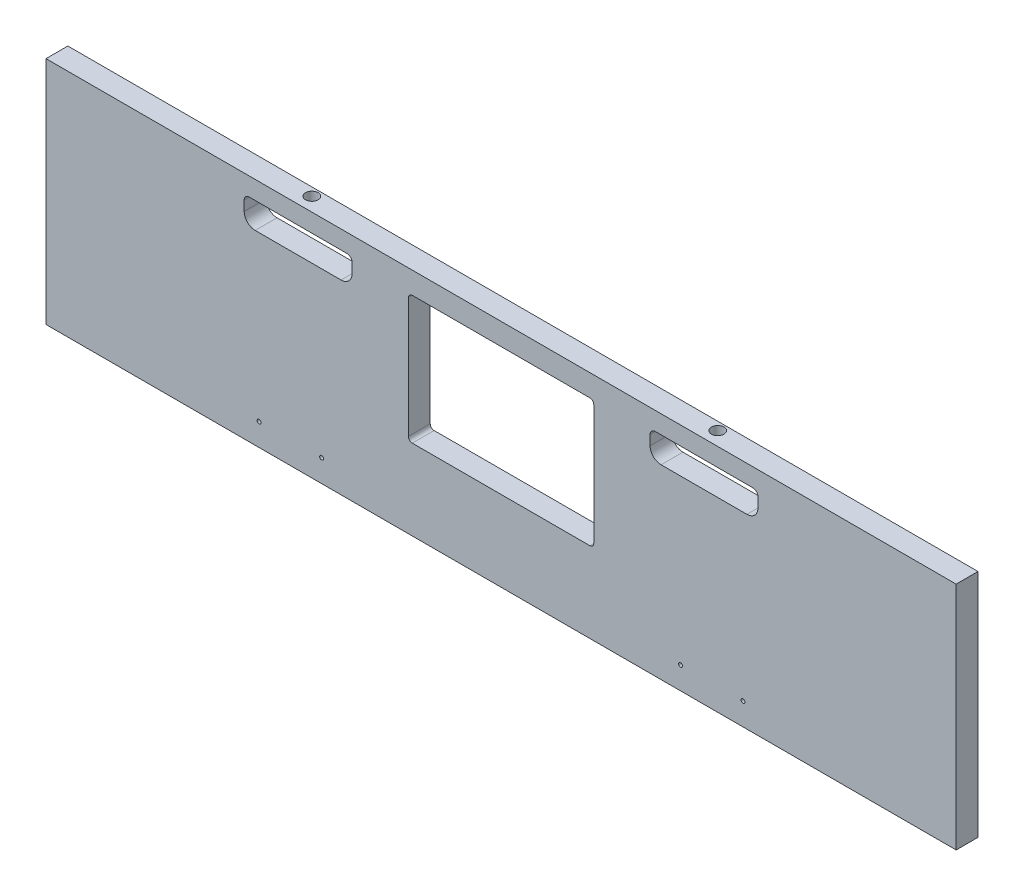
from build123d import *

# Parameters (mm, degrees)
SKETCH2_W          = 740.41
SKETCH2_H          = 187.325
EXTRUDE1_DEPTH     = 17.78
SKETCH3_R          = 1.5875
CUT_EXTRUDE1_DEPTH = 17.78
SKETCH4_R          = 5.08
CUT_EXTRUDE2_DEPTH = 14.859


with BuildPart() as part:
    # Sketch2 → Extrude1 (new body)
    with BuildSketch(Plane.XY):
        with Locations((-233.045, -5408.6125)):
            Rectangle(SKETCH2_W, SKETCH2_H)
    extrude(amount=-EXTRUDE1_DEPTH)

    # Sketch3 → Cut-Extrude1 (cut)
    with BuildSketch(Plane.XY):
        with Locations((-429.895, -5484.0124)):
            Circle(SKETCH3_R)
        with Locations((-379.095, -5484.0124)):
            Circle(SKETCH3_R)
        with Locations((-86.995, -5484.0124)):
            Circle(SKETCH3_R)
        with Locations((-36.195, -5484.0124)):
            Circle(SKETCH3_R)
        with BuildLine():
            Line((-308.45125, -5335.905), (-308.45125, -5433.695))
            ThreePointArc((-308.45125, -5433.695), (-307.52131403, -5435.94006403), (-305.27625, -5436.87))
            Line((-305.27625, -5436.87), (-160.81375, -5436.87))
            ThreePointArc((-160.81375, -5436.87), (-158.56868597, -5435.94006403), (-157.63875, -5433.695))
            Line((-157.63875, -5433.695), (-157.63875, -5335.905))
            ThreePointArc((-157.63875, -5335.905), (-158.56868597, -5333.65993597), (-160.81375, -5332.73))
            Line((-160.81375, -5332.73), (-305.27625, -5332.73))
            ThreePointArc((-305.27625, -5332.73), (-307.52131403, -5333.65993597), (-308.45125, -5335.905))
        make_face()
        with BuildLine():
            Line((-354.2665, -5334), (-354.2665, -5341.9375))
            ThreePointArc((-354.2665, -5341.9375), (-356.888919435, -5348.268580565), (-363.22, -5350.891))
            Line((-363.22, -5350.891), (-433.07, -5350.891))
            ThreePointArc((-433.07, -5350.891), (-439.401080565, -5348.268580565), (-442.0235, -5341.9375))
            Line((-442.0235, -5341.9375), (-442.0235, -5334))
            ThreePointArc((-442.0235, -5334), (-440.79598452, -5331.03651548), (-437.8325, -5329.809))
            Line((-437.8325, -5329.809), (-358.4575, -5329.809))
            ThreePointArc((-358.4575, -5329.809), (-355.49401548, -5331.03651548), (-354.2665, -5334))
        make_face()
        with BuildLine():
            Line((-102.87, -5350.891), (-33.02, -5350.891))
            ThreePointArc((-33.02, -5350.891), (-26.688919435, -5348.268580565), (-24.0665, -5341.9375))
            Line((-24.0665, -5341.9375), (-24.0665, -5334))
            ThreePointArc((-24.0665, -5334), (-25.29401548, -5331.03651548), (-28.2575, -5329.809))
            Line((-28.2575, -5329.809), (-107.6325, -5329.809))
            ThreePointArc((-107.6325, -5329.809), (-110.59598452, -5331.03651548), (-111.8235, -5334))
            Line((-111.8235, -5334), (-111.8235, -5341.9375))
            ThreePointArc((-111.8235, -5341.9375), (-109.201080565, -5348.268580565), (-102.87, -5350.891))
        make_face()
    extrude(amount=-CUT_EXTRUDE1_DEPTH, mode=Mode.SUBTRACT)

    # Sketch4 → Cut-Extrude2 (cut)
    with BuildSketch(Plane(origin=(0, -5314.95, 0), x_dir=(1, 0, 0), z_dir=(0, 1, 0))):
        with Locations((-67.9699936, 11.187303)):
            Circle(SKETCH4_R)
        with Locations((-398.1699936, 11.187303)):
            Circle(SKETCH4_R)
    extrude(amount=-CUT_EXTRUDE2_DEPTH, mode=Mode.SUBTRACT)


solid = part.part
